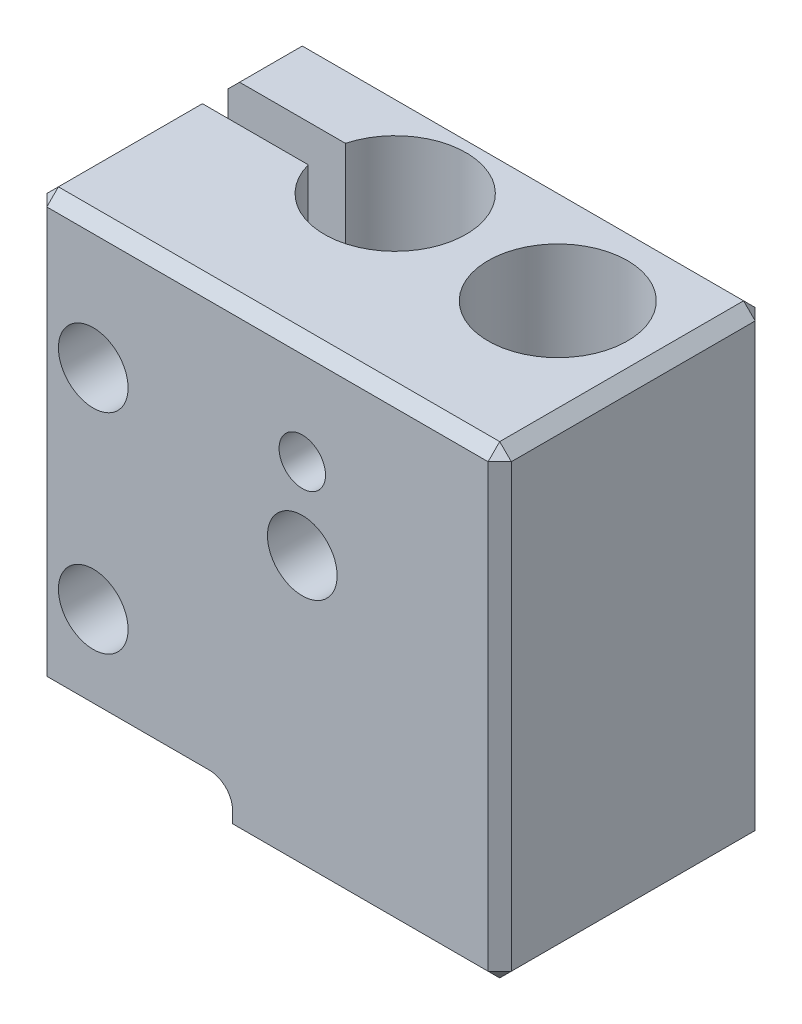
from build123d import *

# Parameters (mm, degrees)
BOSS_EXTRUDE1_DEPTH = 11.5
SKETCH2_R           = 1.5
CUT_EXTRUDE1_DEPTH  = 19.227726134
SKETCH2_3_R         = 0.75
CUT_EXTRUDE2_DEPTH  = 4.5
SKETCH2_4_R         = 1
CUT_EXTRUDE3_DEPTH  = 2
SKETCH2_5_R         = 1.5
CUT_EXTRUDE4_DEPTH  = 3.5
CUT_EXTRUDE5_DEPTH  = 26.144581921
SKETCH3_4_R         = 3
CUT_EXTRUDE6_DEPTH  = 26.144581921
FILLET1_R           = 0.5
CHAMFER1_SIZE       = 0.5


with BuildPart() as part:
    # Sketch1 → Boss-Extrude1 (new body)
    with BuildSketch(Plane.XY):
        Polygon((-10, 10), (10, 10), (10, -10), (-2, -10), (-2, -8.5), (-10, -8.5), align=None)
    extrude(amount=BOSS_EXTRUDE1_DEPTH)

    # Sketch2 → Cut-Extrude1 (cut, through all)
    with BuildSketch(Plane.XY.offset(11.5)):
        with Locations((-7.5, 4.5)):
            Circle(SKETCH2_R)
        with Locations((-7.5, -4.5)):
            Circle(SKETCH2_R)
    extrude(amount=-CUT_EXTRUDE1_DEPTH, mode=Mode.SUBTRACT)

    # Sketch2_3 → Cut-Extrude2 (cut)
    with BuildSketch(Plane.XY.offset(11.5)):
        with Locations((1.5, 5.5)):
            Circle(SKETCH2_3_R)
    extrude(amount=-CUT_EXTRUDE2_DEPTH, mode=Mode.SUBTRACT)

    # Sketch2_4 → Cut-Extrude3 (cut)
    with BuildSketch(Plane.XY.offset(11.5)):
        with Locations((1.5, 5.5)):
            Circle(SKETCH2_4_R)
    extrude(amount=-CUT_EXTRUDE3_DEPTH, mode=Mode.SUBTRACT)

    # Sketch2_5 → Cut-Extrude4 (cut)
    with BuildSketch(Plane.XY.offset(11.5)):
        with Locations((1.5, 2)):
            Circle(SKETCH2_5_R)
    extrude(amount=-CUT_EXTRUDE4_DEPTH, mode=Mode.SUBTRACT)

    # Sketch3 → Cut-Extrude5 (cut, through all)
    with BuildSketch(Plane.XZ.offset(10)):
        with BuildLine():
            Line((-4.943212531, 4.8), (-10, 4.8))
            Line((-10, 4.8), (-10, 3.2))
            Line((-10, 3.2), (-4.943212531, 3.2))
            ThreePointArc((-4.943212531, 3.2), (1.05, 4), (-4.943212531, 4.8))
        make_face()
    extrude(amount=-CUT_EXTRUDE5_DEPTH, mode=Mode.SUBTRACT)

    # Sketch3_4 → Cut-Extrude6 (cut, through all)
    with BuildSketch(Plane.XZ.offset(10)):
        with Locations((5.5, 4.5)):
            Circle(SKETCH3_4_R)
    extrude(amount=-CUT_EXTRUDE6_DEPTH, mode=Mode.SUBTRACT)

    # Fillet1
    fillet1_edges = [part.edges().sort_by_distance(p)[0] for p in [
        (-2, -8.5, 0.475),
        (-2, -10, 9.275),
        (-2, -8.5, 9.275),
        (-2, -10, 0.475),
    ]]
    fillet(fillet1_edges, radius=FILLET1_R)

    # Chamfer1
    chamfer1_edges = [part.edges().sort_by_distance(p)[0] for p in [
        (4.25, -10, 0),
        (-6.25, -8.5, 11.5),
        (-1.853553391, -9.853553391, 0),
        (-2.146446609, -8.646446609, 11.5),
        (-2, -9.25, 0),
        (-2, -9.25, 11.5),
        (-2.146446609, -8.646446609, 0),
        (-1.853553391, -9.853553391, 11.5),
        (10, 10, 5.75),
        (-6.25, -8.5, 0),
        (-10, -8.5, 1.6),
        (-10, 0.75, 0),
        (-10, 10, 1.6),
        (0, 10, 0),
        (10, 0, 0),
        (10, -10, 5.75),
        (-10, -8.5, 8.15),
        (-10, 10, 8.15),
        (-10, 0.75, 11.5),
        (0, 10, 11.5),
        (10, 0, 11.5),
        (4.25, -10, 11.5),
    ]]
    chamfer(chamfer1_edges, length=CHAMFER1_SIZE)


solid = part.part
